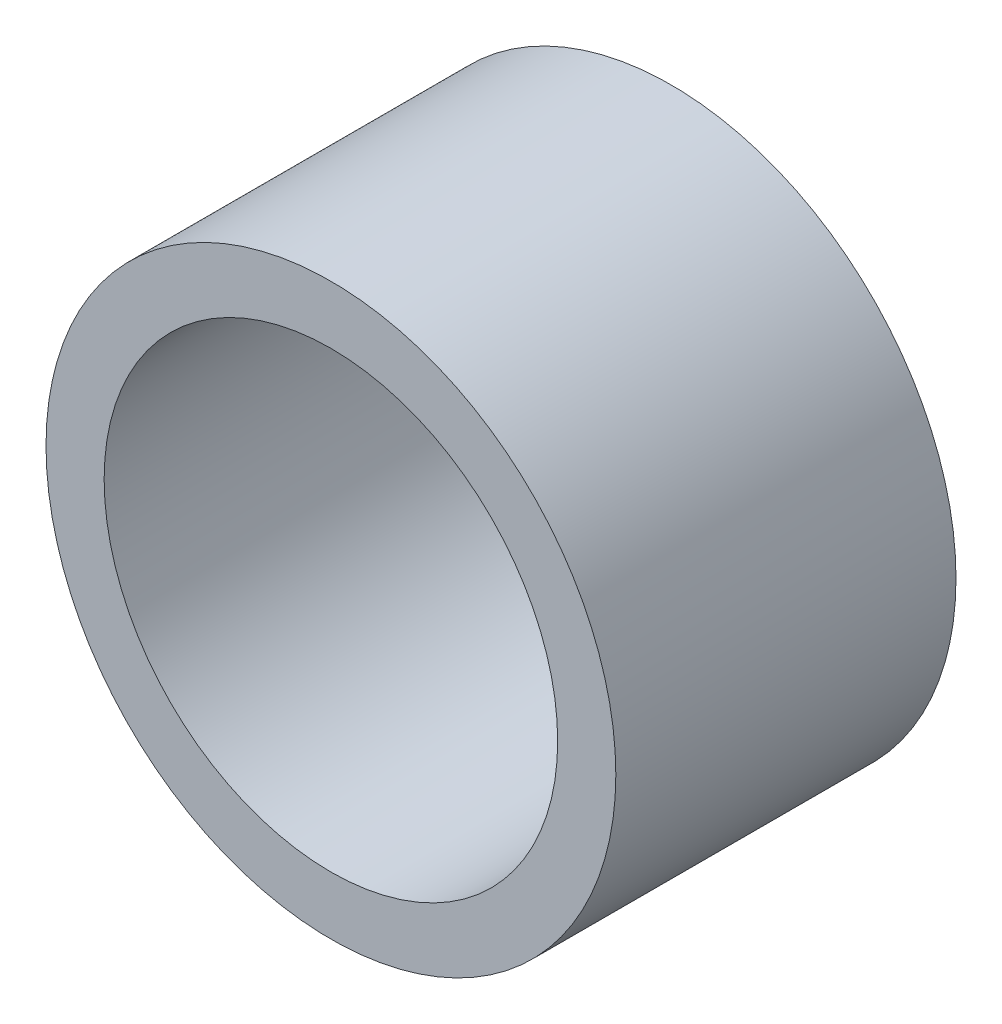
from build123d import *

# Parameters (mm, degrees)
SKETCH3_R                = 5.0255
SKETCH3_R_2              = 4
BOSS_EXTRUDE1_DEPTH      = 3
BOSS_EXTRUDE1_DEPTH_BACK = 3


with BuildPart() as part:
    # Sketch3 → Boss-Extrude1 (new body, two sides)
    with BuildSketch(Plane.XY) as boss_extrude1_sk:
        Circle(SKETCH3_R)
        Circle(SKETCH3_R_2, mode=Mode.SUBTRACT)
    extrude(amount=BOSS_EXTRUDE1_DEPTH)
    extrude(boss_extrude1_sk.sketch, amount=-BOSS_EXTRUDE1_DEPTH_BACK)


solid = part.part
